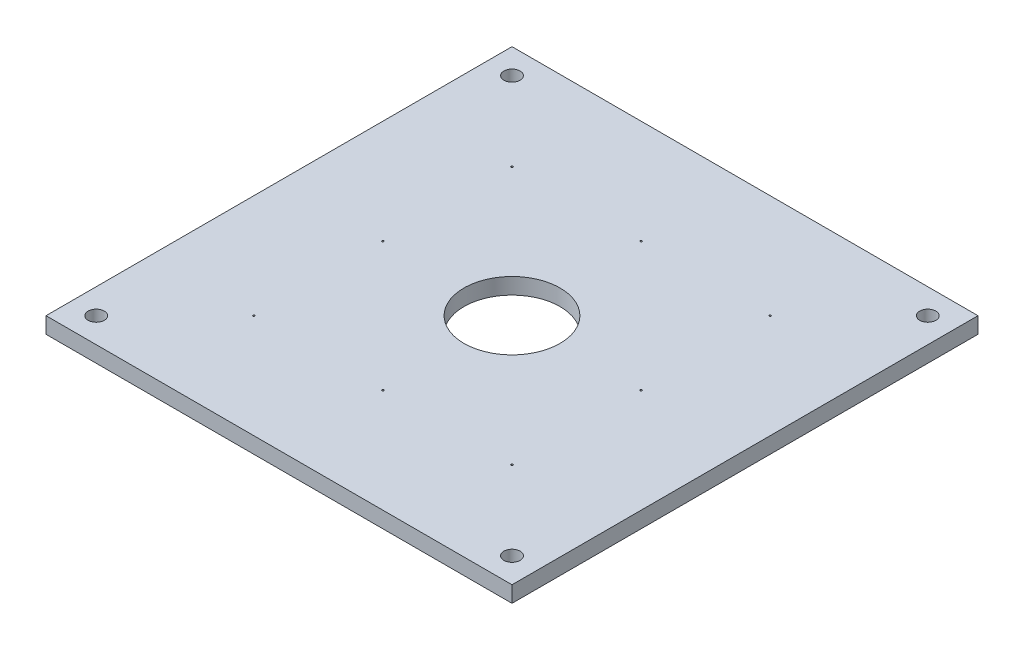
from build123d import *

# Parameters (mm, degrees)
SKETCH1_W           = 130
SKETCH1_H           = 130
SKETCH1_R           = 13.4
SKETCH1_R_2         = 2.25
BOSS_EXTRUDE1_DEPTH = 4.5
SKETCH2_R           = 0.25
CUT_EXTRUDE1_DEPTH  = 5.5


with BuildPart() as part:
    # Sketch1 → Boss-Extrude1 (new body)
    with BuildSketch(Plane(origin=(0, 0, 0), x_dir=(1, 0, 0), z_dir=(0, 1, 0))):
        with Locations((65, 65)):
            Rectangle(SKETCH1_W, SKETCH1_H)
        with Locations((65, 65)):
            Circle(SKETCH1_R, mode=Mode.SUBTRACT)
        with Locations((123, 123)):
            Circle(SKETCH1_R_2, mode=Mode.SUBTRACT)
        with Locations((123, 7)):
            Circle(SKETCH1_R_2, mode=Mode.SUBTRACT)
        with Locations((7, 7)):
            Circle(SKETCH1_R_2, mode=Mode.SUBTRACT)
        with Locations((7, 123)):
            Circle(SKETCH1_R_2, mode=Mode.SUBTRACT)
    extrude(amount=BOSS_EXTRUDE1_DEPTH)

    # Sketch2 → Cut-Extrude1 (cut, through all)
    with BuildSketch(Plane.XZ):
        with Locations((29, -65)):
            Circle(SKETCH2_R)
        with Locations((65, -29)):
            Circle(SKETCH2_R)
        with Locations((101, -65)):
            Circle(SKETCH2_R)
        with Locations((65, -101)):
            Circle(SKETCH2_R)
        with Locations((101, -29)):
            Circle(SKETCH2_R)
        with Locations((29, -29)):
            Circle(SKETCH2_R)
        with Locations((101, -101)):
            Circle(SKETCH2_R)
        with Locations((29, -101)):
            Circle(SKETCH2_R)
    extrude(amount=-CUT_EXTRUDE1_DEPTH, mode=Mode.SUBTRACT)


solid = part.part
